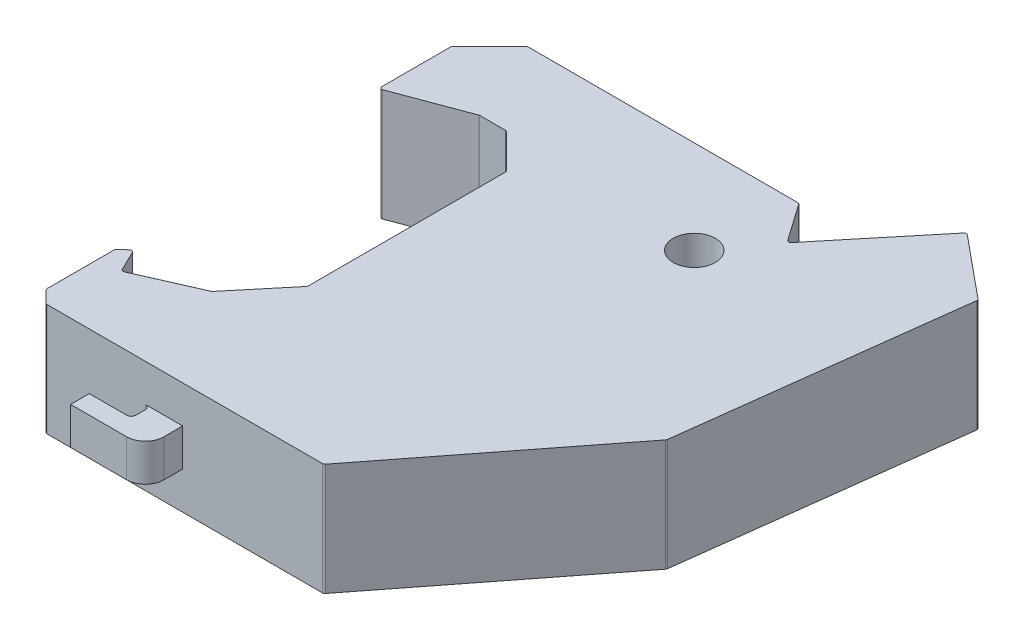
from build123d import *

# Parameters (mm, degrees)
SKETCH1_R           = 2.25
BOSS_EXTRUDE1_DEPTH = 12
SKETCH2_W           = 8
SKETCH2_H           = 4
BOSS_EXTRUDE2_DEPTH = 4
CUT_EXTRUDE1_DEPTH  = 6
CUT_EXTRUDE2_DEPTH  = 13
FILLET1_R           = 0.25


with BuildPart() as part:
    # Sketch1 → Boss-Extrude1 (new body)
    with BuildSketch(Plane(origin=(0, 0, 0), x_dir=(1, 0, 0), z_dir=(0, 1, 0))):
        Polygon((0, 0), (0, 8.7351098), (1.053451476, 9.722150715), (2.345646332, 7.07227283), (9.090891126, 10.042655859), (13.740010344, 15.630633236), (13.740010344, 36.934074296), (9.953212595, 40.720872045), (7.064267003, 40.720872045), (-0.809396561, 37.783381234), (-0.809396561, 45.604675912), (3.258374293, 49.672446766), (32.361506358, 49.672446766), (35.384723628, 45.363574987), (44.093237241, 55.930159978), (50.92671808, 50.298306266), (47.211057141, 20.639259086), (31.116613422, 0), align=None)
        with Locations((31.116613422, 39.692144587)):
            Circle(SKETCH1_R, mode=Mode.SUBTRACT)
    extrude(amount=BOSS_EXTRUDE1_DEPTH)

    # Sketch2 → Boss-Extrude2 (add)
    with BuildSketch(Plane.XY):
        with Locations((12, 6)):
            Rectangle(SKETCH2_W, SKETCH2_H)
    extrude(amount=BOSS_EXTRUDE2_DEPTH)

    # Sketch3 → Cut-Extrude1 (cut)
    with BuildSketch(Plane(origin=(0, 8, 0), x_dir=(1, 0, 0), z_dir=(0, 1, 0))):
        with BuildLine():
            Line((8, 0), (12, 0))
            ThreePointArc((12, 0), (12.353553391, -0.146446609), (12.5, -0.5))
            Line((12.5, -0.5), (12.5, -1.5))
            ThreePointArc((12.5, -1.5), (12.353553391, -1.853553391), (12, -2))
            Line((12, -2), (8, -2))
            Line((8, -2), (8, 0))
        make_face()
        with BuildLine():
            Line((14, -4), (16, -4))
            Line((16, -4), (16, -2))
            ThreePointArc((16, -2), (15.414213562, -3.414213562), (14, -4))
        make_face()
    extrude(amount=-CUT_EXTRUDE1_DEPTH, mode=Mode.SUBTRACT)

    # Sketch4 → Cut-Extrude2 (cut, through all)
    with BuildSketch(Plane(origin=(0, 12, 0), x_dir=(1, 0, 0), z_dir=(0, 1, 0))):
        Polygon((0, 0), (0, 1.364035653), (1.364035653, 0), align=None)
    extrude(amount=-CUT_EXTRUDE2_DEPTH, mode=Mode.SUBTRACT)

    # Fillet1
    fillet1_edges = [part.edges().sort_by_distance(p)[0] for p in [
        (1.364035653, 6, 0),
        (0, 6, -1.364035653),
        (0, 6, -8.7351098),
        (1.053451476, 6, -9.722150715),
        (2.345646332, 6, -7.07227283),
        (9.090891126, 6, -10.042655859),
        (13.740010344, 6, -15.630633236),
        (13.740010344, 6, -36.934074296),
        (9.953212595, 6, -40.720872045),
        (7.064267003, 6, -40.720872045),
        (-0.809396561, 6, -37.783381234),
        (-0.809396561, 6, -45.604675912),
        (3.258374293, 6, -49.672446766),
        (32.361506358, 6, -49.672446766),
        (35.384723628, 6, -45.363574987),
        (44.093237241, 6, -55.930159978),
        (50.92671808, 6, -50.298306266),
        (47.211057141, 6, -20.639259086),
        (31.116613422, 6, 0),
    ]]
    fillet(fillet1_edges, radius=FILLET1_R)


solid = part.part
